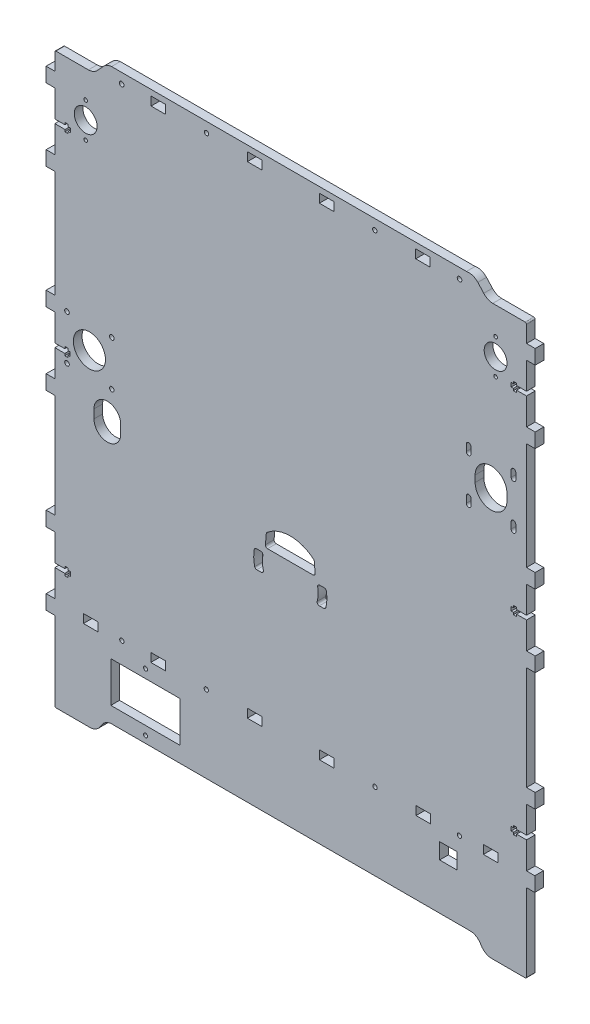
from build123d import *

# Parameters (mm, degrees)
SKETCH_1_R      = 7.9
SKETCH_1_R_2    = 1.6
SKETCH_1_R_3    = 1.5
SKETCH_1_R_4    = 11.1
SKETCH_1_R_5    = 1.4
SKETCH_1_R_6    = 1.25
SKETCH_1_W      = 10
SKETCH_1_H      = 6
SKETCH_1_W_2    = 12.1
SKETCH_1_H_2    = 11
SKETCH_1_W_3    = 48
SKETCH_1_H_3    = 28
EXTRUDE_1_DEPTH = 6


with BuildPart() as part:
    # Эскиз1 → Бобышка-Вытянуть1 (new body)
    with BuildSketch(Plane.XY):
        with BuildLine():
            Line((-197.487602206, 21.424334113), (-197.486561677, 20.054248176))
            Line((-197.486561677, 20.054248176), (-195.286801854, 20.054248176))
            Line((-195.286801854, 20.054248176), (-195.286817832, 21.426921304))
            Line((-195.286817832, 21.426921304), (-195.286801854, 21.454129382))
            Line((-195.286801854, 21.454129382), (-193.786801854, 21.454129382))
            Line((-193.786801854, 21.454129382), (-193.786801854, 24.24851002))
            Line((-193.786801854, 24.24851002), (-193.786785876, 24.275718097))
            Line((-193.786785876, 24.275718097), (-195.286785876, 24.275718097))
            Line((-195.286785876, 24.275718097), (-195.287641863, 25.64942725))
            Line((-195.287641863, 25.64942725), (-195.287642523, 25.676635332))
            Line((-195.287642523, 25.676635332), (-197.487642934, 25.676635332))
            Line((-197.487642934, 25.676635332), (-197.487638249, 25.64942725))
            Line((-197.487638249, 25.64942725), (-197.487435772, 24.276635347))
            Line((-197.487435772, 24.276635347), (-204.436337757, 24.276635347))
            Line((-204.436337757, 24.276635347), (-204.436337757, 42.876635347))
            Line((-204.436337757, 42.876635347), (-210.436337757, 42.876635347))
            Line((-210.436337757, 42.876635347), (-210.436337757, 52.876635347))
            Line((-210.436337757, 52.876635347), (-204.436337757, 52.876635347))
            Line((-204.436337757, 52.876635347), (-204.436337757, 127.036635347))
            Line((-204.436337757, 127.036635347), (-210.436337757, 127.036635347))
            Line((-210.436337757, 127.036635347), (-210.436337757, 137.036635347))
            Line((-210.436337757, 137.036635347), (-204.436337757, 137.036635347))
            Line((-204.436337757, 137.036635347), (-204.436337757, 155.636635347))
            Line((-204.436337757, 155.636635347), (-197.387139854, 155.636635347))
            Line((-197.387139854, 155.636635347), (-197.387139854, 154.236531323))
            Line((-197.387139854, 154.236531323), (-195.186317271, 154.236531323))
            Line((-195.186317271, 154.236531323), (-195.186317271, 155.618966061))
            Line((-195.186317271, 155.618966061), (-193.715479854, 155.618966061))
            Line((-193.715479854, 155.618966061), (-193.715479854, 158.418966061))
            Line((-193.715479854, 158.418966061), (-195.218141804, 158.418966061))
            Line((-195.218141804, 158.418966061), (-195.218141804, 159.836635347))
            Line((-195.218141804, 159.836635347), (-197.418142215, 159.836635347))
            Line((-197.418142215, 159.836635347), (-197.418142215, 158.436635347))
            Line((-197.418142215, 158.436635347), (-204.436337757, 158.436635347))
            Line((-204.436337757, 158.436635347), (-204.436337757, 177.036635347))
            Line((-204.436337757, 177.036635347), (-210.436337757, 177.036635347))
            Line((-210.436337757, 177.036635347), (-210.436337757, 187.036635347))
            Line((-210.436337757, 187.036635347), (-204.436337757, 187.036635347))
            Line((-204.436337757, 187.036635347), (-204.436337757, 198.258791497))
            ThreePointArc((-204.436337757, 198.258791497), (-204.328344016, 199.026576962), (-203.670309603, 199.436635347))
            Line((-203.670309603, 199.436635347), (-181.21366511, 199.436635347))
            ThreePointArc((-181.21366511, 199.436635347), (-177.786697283, 200.165852645), (-174.944614984, 202.214860835))
            Line((-174.944614984, 202.214860835), (-170.849061928, 206.694475052))
            ThreePointArc((-170.849061928, 206.694475052), (-168.285810468, 208.606816645), (-165.197330366, 209.436635347))
            Line((-165.197330366, 209.436635347), (80.233513167, 209.436635347))
            ThreePointArc((80.233513167, 209.436635347), (84.503563818, 209.155552648), (88.09552196, 206.829573983))
            Line((88.09552196, 206.829573983), (92.195746981, 202.354235654))
            ThreePointArc((92.195746981, 202.354235654), (95.023116575, 200.232431533), (98.467355239, 199.436635347))
            Line((98.467355239, 199.436635347), (120.843662243, 199.436635347))
            ThreePointArc((120.843662243, 199.436635347), (121.494200482, 199.167173586), (121.763662243, 198.516635347))
            Line((121.763662243, 198.516635347), (121.763662243, 187.036635347))
            Line((121.763662243, 187.036635347), (127.763662243, 187.036635347))
            Line((127.763662243, 187.036635347), (127.763662243, 177.036635347))
            Line((127.763662243, 177.036635347), (121.763662243, 177.036635347))
            Line((121.763662243, 177.036635347), (121.763662243, 158.436635347))
            Line((121.763662243, 158.436635347), (114.851661036, 158.436635347))
            Line((114.851661036, 158.436635347), (114.851661036, 159.836739372))
            Line((114.851661036, 159.836739372), (112.650838454, 159.836739372))
            Line((112.650838454, 159.836739372), (112.651660526, 158.436858407))
            Line((112.651660526, 158.436858407), (111.151660785, 158.435977541))
            Line((111.151660785, 158.435977541), (111.15330453, 155.636894735))
            Line((111.15330453, 155.636894735), (112.653304271, 155.637775601))
            Line((112.653304271, 155.637775601), (112.654126952, 154.236858346))
            Line((112.654126952, 154.236858346), (114.854127367, 154.236805006))
            Line((114.854127367, 154.236805006), (114.854161306, 155.636635347))
            Line((114.854161306, 155.636635347), (121.763662346, 155.636635347))
            Line((121.763662346, 155.636635347), (121.763662346, 137.036635347))
            Line((121.763662346, 137.036635347), (127.735522472, 137.036635347))
            Line((127.735522472, 137.036635347), (127.735522472, 127.036635347))
            Line((127.735522472, 127.036635347), (121.735522472, 127.036635347))
            Line((121.735522472, 127.036635347), (121.735522472, 52.876635347))
            Line((121.735522472, 52.876635347), (127.735522472, 52.876635347))
            Line((127.735522472, 52.876635347), (127.735522472, 42.876635347))
            Line((127.735522472, 42.876635347), (121.73141262, 42.876635347))
            Line((121.73141262, 42.876635347), (121.73141262, 24.276635347))
            Line((121.73141262, 24.276635347), (114.867621421, 24.276635347))
            Line((114.867621421, 24.276635347), (114.867616759, 24.303704553))
            Line((114.867616759, 24.303704553), (114.867380328, 25.676569221))
            Line((114.867380328, 25.676569221), (112.666557749, 25.676190201))
            Line((112.666557749, 25.676190201), (112.667616243, 24.303378605))
            Line((112.667616243, 24.303378605), (112.667620905, 24.276309399))
            Line((112.667620905, 24.276309399), (111.167621337, 24.275170207))
            Line((111.167621337, 24.275170207), (111.169742471, 21.503156931))
            Line((111.169742471, 21.503156931), (111.169747133, 21.476087726))
            Line((111.169747133, 21.476087726), (112.6697467, 21.477226918))
            Line((112.6697467, 21.477226918), (112.670805981, 20.103379031))
            Line((112.670805981, 20.103379031), (112.670810643, 20.076309825))
            Line((112.670810643, 20.076309825), (114.87081103, 20.076635363))
            Line((114.87081103, 20.076635363), (114.870806368, 20.103704568))
            Line((114.870806368, 20.103704568), (114.87060387, 21.476635347))
            Line((114.87060387, 21.476635347), (121.780104909, 21.476635347))
            Line((121.780104909, 21.476635347), (121.780104909, 2.876635347))
            Line((121.780104909, 2.876635347), (127.777161917, 2.876635347))
            Line((127.777161917, 2.876635347), (127.777161917, -7.123364653))
            Line((127.777161917, -7.123364653), (121.777161917, -7.123364653))
            Line((121.777161917, -7.123364653), (121.777161917, -78.853364653))
            Line((121.777161917, -78.853364653), (127.777161917, -78.853364653))
            Line((127.777161917, -78.853364653), (127.777161917, -88.853364653))
            Line((127.777161917, -88.853364653), (121.865168685, -88.853364653))
            Line((121.865168685, -88.853364653), (121.865168685, -107.433364653))
            Line((121.865168685, -107.433364653), (114.865167478, -107.433364653))
            Line((114.865167478, -107.433364653), (114.865167478, -106.033260628))
            Line((114.865167478, -106.033260628), (112.664344896, -106.033260628))
            Line((112.664344896, -106.033260628), (112.665166968, -107.433141593))
            Line((112.665166968, -107.433141593), (111.165167227, -107.434022459))
            Line((111.165167227, -107.434022459), (111.166810972, -110.233105265))
            Line((111.166810972, -110.233105265), (112.666810713, -110.232224399))
            Line((112.666810713, -110.232224399), (112.667633394, -111.633141654))
            Line((112.667633394, -111.633141654), (114.870838426, -111.633195072))
            Line((114.870838426, -111.633195072), (114.870872365, -110.233364653))
            Line((114.870872365, -110.233364653), (121.763662243, -110.233364653))
            Line((121.763662243, -110.233364653), (121.763662243, -128.843364653))
            Line((121.763662243, -128.843364653), (127.47801658, -128.843364653))
            Line((127.47801658, -128.843364653), (127.47801658, -138.843364653))
            Line((127.47801658, -138.843364653), (121.763662243, -138.843364653))
            Line((121.763662243, -138.843364653), (121.763662243, -192.691567269))
            ThreePointArc((121.763662243, -192.691567269), (121.316582891, -193.181526037), (120.669471449, -193.327081261))
            Line((120.669471449, -193.327081261), (97.669079588, -193.327081261))
            ThreePointArc((97.669079588, -193.327081261), (94.116647531, -192.50805485), (91.239822569, -190.268756762))
            Line((91.239822569, -190.268756762), (89.183118423, -187.249103667))
            ThreePointArc((89.183118423, -187.249103667), (86.263995882, -185.009182159), (82.671740657, -184.212798349))
            Line((82.671740657, -184.212798349), (-165.296570174, -184.212798349))
            ThreePointArc((-165.296570174, -184.212798349), (-168.886723993, -185.281052755), (-171.669107354, -187.788783751))
            Line((-171.669107354, -187.788783751), (-173.724235811, -190.809509456))
            ThreePointArc((-173.724235811, -190.809509456), (-176.639720291, -193.057976183), (-180.232351887, -193.863364653))
            Line((-180.232351887, -193.863364653), (-203.35849545, -193.863364653))
            ThreePointArc((-203.35849545, -193.863364653), (-204.158043867, -193.595905372), (-204.436337757, -192.800063271))
            Line((-204.436337757, -192.800063271), (-204.436337757, -138.843364653))
            Line((-204.436337757, -138.843364653), (-210.431075973, -138.843364653))
            Line((-210.431075973, -138.843364653), (-210.431075973, -128.843364653))
            Line((-210.431075973, -128.843364653), (-204.436337757, -128.843364653))
            Line((-204.436337757, -128.843364653), (-204.436337757, -110.233364653))
            Line((-204.436337757, -110.233364653), (-197.523921698, -110.233364653))
            Line((-197.523921698, -110.233364653), (-197.523672393, -111.68096837))
            Line((-197.523672393, -111.68096837), (-195.335013115, -111.679449577))
            Line((-195.335013115, -111.679449577), (-195.336806264, -110.279844178))
            Line((-195.336806264, -110.279844178), (-193.677914745, -110.277769726))
            Line((-193.677914745, -110.277769726), (-193.68325579, -107.284374899))
            Line((-193.68325579, -107.284374899), (-195.328101329, -107.286501137))
            Line((-195.328101329, -107.286501137), (-195.329942101, -105.895501094))
            Line((-195.329942101, -105.895501094), (-197.490847394, -105.897039343))
            Line((-197.490847394, -105.897039343), (-197.490620059, -107.433364653))
            Line((-197.490620059, -107.433364653), (-204.436337757, -107.433364653))
            Line((-204.436337757, -107.433364653), (-204.436337757, -88.853364653))
            Line((-204.436337757, -88.853364653), (-210.436337757, -88.853364653))
            Line((-210.436337757, -88.853364653), (-210.436337757, -78.853364653))
            Line((-210.436337757, -78.853364653), (-204.436337757, -78.853364653))
            Line((-204.436337757, -78.853364653), (-204.436337757, -7.123364653))
            Line((-204.436337757, -7.123364653), (-210.436337757, -7.123364653))
            Line((-210.436337757, -7.123364653), (-210.436337757, 2.876635347))
            Line((-210.436337757, 2.876635347), (-204.436337757, 2.876635347))
            Line((-204.436337757, 2.876635347), (-204.436337757, 21.456635347))
            Line((-204.436337757, 21.456635347), (-204.436337757, 21.476635347))
            Line((-204.436337757, 21.476635347), (-197.487641927, 21.476635347))
            Line((-197.487641927, 21.476635347), (-197.487602206, 21.424334113))
        make_face()
        with Locations((-183.086337757, 168.436635347)):
            Circle(SKETCH_1_R, mode=Mode.SUBTRACT)
        with Locations((100.408400459, 168.436635347)):
            Circle(SKETCH_1_R, mode=Mode.SUBTRACT)
        with Locations((-158.141599541, 202.436635347)):
            Circle(SKETCH_1_R_2, mode=Mode.SUBTRACT)
        with Locations((75.458400459, 202.436635347)):
            Circle(SKETCH_1_R_2, mode=Mode.SUBTRACT)
        with Locations((16.858400459, 202.436635347)):
            Circle(SKETCH_1_R_3, mode=Mode.SUBTRACT)
        with Locations((-99.541599541, 202.436635347)):
            Circle(SKETCH_1_R_3, mode=Mode.SUBTRACT)
        with Locations((-196.006387984, 47.305988871)):
            Circle(SKETCH_1_R_2, mode=Mode.SUBTRACT)
        with Locations((-165.006387984, 16.305988871)):
            Circle(SKETCH_1_R_2, mode=Mode.SUBTRACT)
        with Locations((-196.006387984, 16.305988871)):
            Circle(SKETCH_1_R_2, mode=Mode.SUBTRACT)
        with Locations((-180.506387984, 31.805988871)):
            Circle(SKETCH_1_R_4, mode=Mode.SUBTRACT)
        with Locations((-165.006387984, 47.305988871)):
            Circle(SKETCH_1_R_2, mode=Mode.SUBTRACT)
        with Locations((75.383662243, -130.863364653)):
            Circle(SKETCH_1_R_3, mode=Mode.SUBTRACT)
        with Locations((16.983662243, -130.863364653)):
            Circle(SKETCH_1_R_3, mode=Mode.SUBTRACT)
        with Locations((-99.656337757, -130.863364653)):
            Circle(SKETCH_1_R_3, mode=Mode.SUBTRACT)
        with Locations((-158.056337757, -130.863364653)):
            Circle(SKETCH_1_R_3, mode=Mode.SUBTRACT)
        with Locations((-141.692424291, -179.412798349)):
            Circle(SKETCH_1_R_5, mode=Mode.SUBTRACT)
        with Locations((-141.692424291, -139.412798349)):
            Circle(SKETCH_1_R_5, mode=Mode.SUBTRACT)
        with Locations((100.408400459, 180.436635347)):
            Circle(SKETCH_1_R_6, mode=Mode.SUBTRACT)
        with Locations((100.408400459, 156.436635347)):
            Circle(SKETCH_1_R_6, mode=Mode.SUBTRACT)
        with Locations((-183.086337757, 180.436635347)):
            Circle(SKETCH_1_R_6, mode=Mode.SUBTRACT)
        with Locations((-183.086337757, 156.436635347)):
            Circle(SKETCH_1_R_6, mode=Mode.SUBTRACT)
        with Locations((-16.416337757, -130.863364653)):
            Rectangle(SKETCH_1_W, SKETCH_1_H, mode=Mode.SUBTRACT)
        with Locations((-66.256337757, -130.863364653)):
            Rectangle(SKETCH_1_W, SKETCH_1_H, mode=Mode.SUBTRACT)
        with Locations((67.713662243, -146.827081261)):
            Rectangle(SKETCH_1_W_2, SKETCH_1_H_2, mode=Mode.SUBTRACT)
        with Locations((-133.056337757, -130.863364653)):
            Rectangle(SKETCH_1_W, SKETCH_1_H, mode=Mode.SUBTRACT)
        with Locations((-179.636337757, -130.863364653)):
            Rectangle(SKETCH_1_W, SKETCH_1_H, mode=Mode.SUBTRACT)
        with Locations((96.963662243, -130.863364653)):
            Rectangle(SKETCH_1_W, SKETCH_1_H, mode=Mode.SUBTRACT)
        with Locations((50.383662243, -130.863364653)):
            Rectangle(SKETCH_1_W, SKETCH_1_H, mode=Mode.SUBTRACT)
        with BuildLine():
            Line((-18.134599873, -29.194011129), (-21.184312759, -29.194011129))
            ThreePointArc((-21.184312759, -29.194011129), (-22.342493839, -29.740797309), (-22.65630504, -30.982522347))
            ThreePointArc((-22.65630504, -30.982522347), (-22.309250666, -35.408837109), (-22.983068573, -39.797308203))
            ThreePointArc((-22.983068573, -39.797308203), (-22.72917458, -41.103666451), (-21.536477135, -41.694011129))
            Line((-21.536477135, -41.694011129), (-18.440328783, -41.694011129))
            ThreePointArc((-18.440328783, -41.694011129), (-17.510284763, -41.370879057), (-16.980943477, -40.540701957))
            ThreePointArc((-16.980943477, -40.540701957), (-16.309095275, -35.507678983), (-16.655943039, -30.441872344))
            ThreePointArc((-16.655943039, -30.441872344), (-17.167182739, -29.547667337), (-18.134599873, -29.194011129))
        make_face(mode=Mode.SUBTRACT)
        with BuildLine():
            Line((-64.7445198, -41.694011128), (-61.648371447, -41.694011128))
            ThreePointArc((-61.648371447, -41.694011128), (-60.455674003, -41.103666451), (-60.201780009, -39.797308203))
            ThreePointArc((-60.201780009, -39.797308203), (-60.875597917, -35.408837109), (-60.528543542, -30.982522347))
            ThreePointArc((-60.528543542, -30.982522347), (-60.842354744, -29.740797309), (-62.000535824, -29.194011129))
            Line((-62.000535824, -29.194011129), (-65.05024871, -29.194011129))
            ThreePointArc((-65.05024871, -29.194011129), (-66.017665844, -29.547667337), (-66.528905544, -30.441872344))
            ThreePointArc((-66.528905544, -30.441872344), (-66.875753307, -35.507678983), (-66.203905105, -40.540701957))
            ThreePointArc((-66.203905105, -40.540701957), (-65.67456382, -41.370879057), (-64.7445198, -41.694011128))
        make_face(mode=Mode.SUBTRACT)
        with BuildLine():
            Line((-58.18830834, -16.824477467), (-58.795688036, -23.766859164))
            ThreePointArc((-58.795688036, -23.766859164), (-58.407311994, -24.91097809), (-57.301395989, -25.397592779))
            Line((-57.301395989, -25.397592779), (-25.883452594, -25.397592779))
            ThreePointArc((-25.883452594, -25.397592779), (-24.777536589, -24.91097809), (-24.389160547, -23.766859164))
            Line((-24.389160547, -23.766859164), (-24.996540243, -16.824477467))
            ThreePointArc((-24.996540243, -16.824477467), (-25.15785371, -16.267338924), (-25.518477328, -15.813052674))
            ThreePointArc((-25.518477328, -15.813052674), (-41.592424291, -9.897592775), (-57.666371255, -15.813052674))
            ThreePointArc((-57.666371255, -15.813052674), (-58.026994873, -16.267338924), (-58.18830834, -16.824477467))
        make_face(mode=Mode.SUBTRACT)
        with Locations((-141.692424291, -159.412798349)):
            Rectangle(SKETCH_1_W_3, SKETCH_1_H_3, mode=Mode.SUBTRACT)
        with Locations((-132.841599541, 202.436635347)):
            Rectangle(SKETCH_1_W, SKETCH_1_H, mode=Mode.SUBTRACT)
        with Locations((50.158400459, 202.436635347)):
            Rectangle(SKETCH_1_W, SKETCH_1_H, mode=Mode.SUBTRACT)
        with Locations((-66.241599541, 202.436635347)):
            Rectangle(SKETCH_1_W, SKETCH_1_H, mode=Mode.SUBTRACT)
        with Locations((-16.441599541, 202.436635347)):
            Rectangle(SKETCH_1_W, SKETCH_1_H, mode=Mode.SUBTRACT)
        with BuildLine():
            Line((-158.856387984, -7.694011129), (-158.856387984, -1.694011129))
            ThreePointArc((-158.856387984, -1.694011129), (-168.106387984, 7.555988871), (-177.356387984, -1.694011129))
            Line((-177.356387984, -1.694011129), (-177.356387984, -7.694011129))
            ThreePointArc((-177.356387984, -7.694011129), (-168.106387984, -16.944011129), (-158.856387984, -7.694011129))
        make_face(mode=Mode.SUBTRACT)
        with BuildLine():
            Line((86.257214298, 90.555988871), (86.257214298, 86.055988871))
            ThreePointArc((86.257214298, 86.055988871), (97.257214298, 75.055988871), (108.257214298, 86.055988871))
            Line((108.257214298, 86.055988871), (108.257214298, 90.555988871))
            ThreePointArc((108.257214298, 90.555988871), (97.257214298, 101.555988871), (86.257214298, 90.555988871))
        make_face(mode=Mode.SUBTRACT)
        with BuildLine():
            Line((111.157214298, 75.055988871), (111.157214298, 70.555988871))
            ThreePointArc((111.157214298, 70.555988871), (112.757214298, 68.955988871), (114.357214298, 70.555988871))
            Line((114.357214298, 70.555988871), (114.357214298, 75.055988871))
            ThreePointArc((114.357214298, 75.055988871), (112.757214298, 76.655988871), (111.157214298, 75.055988871))
        make_face(mode=Mode.SUBTRACT)
        with BuildLine():
            Line((114.357214298, 101.555988871), (114.357214298, 106.055988871))
            ThreePointArc((114.357214298, 106.055988871), (112.757214298, 107.655988871), (111.157214298, 106.055988871))
            Line((111.157214298, 106.055988871), (111.157214298, 101.555988871))
            ThreePointArc((111.157214298, 101.555988871), (112.757214298, 99.955988871), (114.357214298, 101.555988871))
        make_face(mode=Mode.SUBTRACT)
        with BuildLine():
            Line((80.157214298, 75.055988871), (80.157214298, 70.555988871))
            ThreePointArc((80.157214298, 70.555988871), (81.757214298, 68.955988871), (83.357214298, 70.555988871))
            Line((83.357214298, 70.555988871), (83.357214298, 75.055988871))
            ThreePointArc((83.357214298, 75.055988871), (81.757214298, 76.655988871), (80.157214298, 75.055988871))
        make_face(mode=Mode.SUBTRACT)
        with BuildLine():
            Line((83.357214298, 101.555988871), (83.357214298, 106.055988871))
            ThreePointArc((83.357214298, 106.055988871), (81.757214298, 107.655988871), (80.157214298, 106.055988871))
            Line((80.157214298, 106.055988871), (80.157214298, 101.555988871))
            ThreePointArc((80.157214298, 101.555988871), (81.757214298, 99.955988871), (83.357214298, 101.555988871))
        make_face(mode=Mode.SUBTRACT)
    extrude(amount=EXTRUDE_1_DEPTH)


solid = part.part
